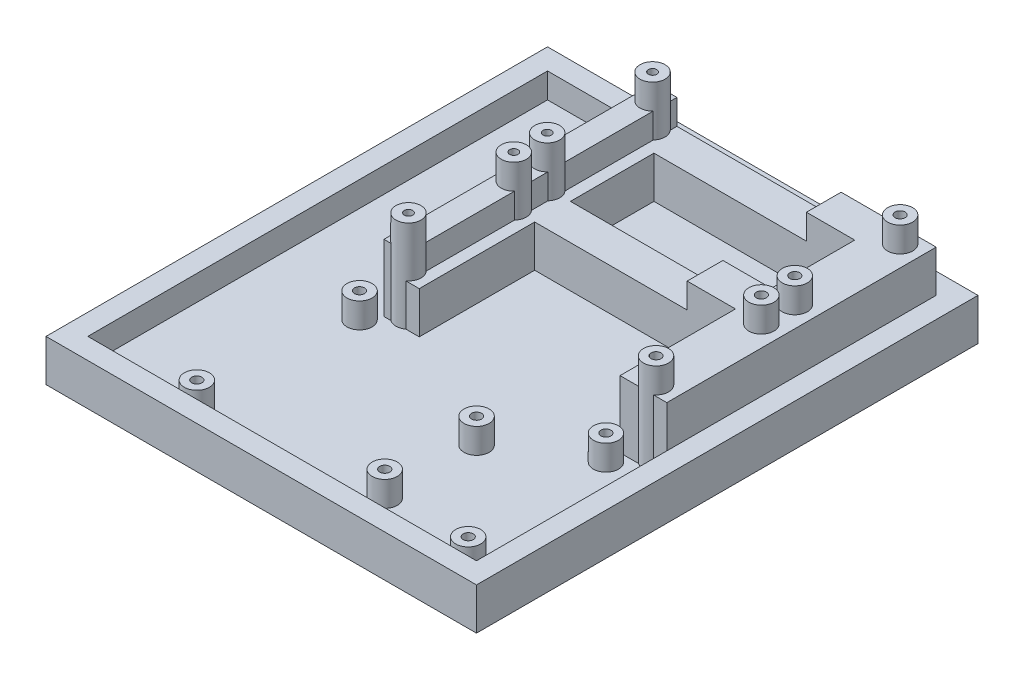
from build123d import *

# Parameters (mm, degrees)
SKETCH1_W            = 152.4
SKETCH1_H            = 152.4
BOSS_EXTRUDE1_DEPTH  = 5.08
SKETCH6_R            = 3.81
BOSS_EXTRUDE3_DEPTH  = 7.62
SKETCH7_W            = 152.4
SKETCH7_H            = 152.4
SKETCH7_W_2          = 139.7
SKETCH7_H_2          = 139.7
BOSS_EXTRUDE4_DEPTH  = 7.62
SKETCH9_R            = 3.81
BOSS_EXTRUDE6_DEPTH  = 27.94
SKETCH11_W           = 85.963722039
SKETCH11_H           = 81.851496928
BOSS_EXTRUDE9_DEPTH  = 20.32
SKETCH12_W           = 61.01453669
SKETCH12_H           = 25.385301209
SKETCH12_H_2         = 35.074856928
CUT_EXTRUDE1_DEPTH   = 20.32
SKETCH14_W           = 46.335678953
SKETCH14_H           = 46.77664
CUT_EXTRUDE2_DEPTH   = 7.62
SKETCH15_R           = 1.524
CUT_EXTRUDE3_DEPTH   = 3.81
SKETCH16_R           = 1.524
CUT_EXTRUDE4_DEPTH   = 3.81
BOSS_EXTRUDE10_START = -12.7
SKETCH18_W           = 165.1
SKETCH18_H           = 165.1
SKETCH18_W_2         = 152.4
SKETCH18_H_2         = 152.4
BOSS_EXTRUDE10_DEPTH = 12.7
SKETCH22_W           = 195.571726543
SKETCH22_H           = 199.98311887
SKETCH22_W_2         = 152.4
SKETCH22_H_2         = 152.4
CUT_EXTRUDE5_DEPTH   = 13.7
SKETCH24_W           = 21.59
SKETCH24_H           = 152.4
CUT_EXTRUDE6_DEPTH   = 13.7
SKETCH25_W           = 6.35
SKETCH25_H           = 139.7
BOSS_EXTRUDE11_DEPTH = 7.62
SKETCH26_W           = 3.556
SKETCH26_H           = 81.851496928
CUT_EXTRUDE7_DEPTH   = 7.62
BOSS_EXTRUDE12_START = -15.24
SKETCH28_R           = 3.81
SKETCH28_R_2         = 1.27
BOSS_EXTRUDE12_DEPTH = 15.24
CUT_EXTRUDE8_DEPTH   = 15.24


with BuildPart() as part:
    # Sketch1 → Boss-Extrude1 (new body)
    with BuildSketch(Plane(origin=(0, 0, 0), x_dir=(1, 0, 0), z_dir=(0, 1, 0))):
        Rectangle(SKETCH1_W, SKETCH1_H)
    extrude(amount=BOSS_EXTRUDE1_DEPTH)

    # Sketch6 → Boss-Extrude3 (add)
    with BuildSketch(Plane(origin=(0, 5.08, 0), x_dir=(1, 0, 0), z_dir=(0, 1, 0))):
        with Locations((62.26048, -64.77)):
            Circle(SKETCH6_R)
        with Locations((-20.21078, -64.77)):
            Circle(SKETCH6_R)
        with Locations((31.81096, -59.69)):
            Circle(SKETCH6_R)
        with Locations((31.81096, -31.78048)):
            Circle(SKETCH6_R)
        with Locations((55.90032, -16.55064)):
            Circle(SKETCH6_R)
        with Locations((-18.97888, -16.55064)):
            Circle(SKETCH6_R)
    extrude(amount=BOSS_EXTRUDE3_DEPTH)

    # Sketch7 → Boss-Extrude4 (add)
    with BuildSketch(Plane(origin=(0, 5.08, 0), x_dir=(1, 0, 0), z_dir=(0, 1, 0))):
        Rectangle(SKETCH7_W, SKETCH7_H)
        Rectangle(SKETCH7_W_2, SKETCH7_H_2, mode=Mode.SUBTRACT)
    extrude(amount=BOSS_EXTRUDE4_DEPTH)

    # Sketch9 → Boss-Extrude6 (add)
    with BuildSketch(Plane(origin=(0, 5.08, 0), x_dir=(1, 0, 0), z_dir=(0, 1, 0))):
        with Locations((63.5, -8.93064)):
            Circle(SKETCH9_R)
        with Locations((-11.7348, -8.93064)):
            Circle(SKETCH9_R)
        with Locations((63.5, 23.07336)):
            Circle(SKETCH9_R)
        with Locations((-11.7348, 23.07336)):
            Circle(SKETCH9_R)
        with Locations((-11.7348, 33.23336)):
            Circle(SKETCH9_R)
        with Locations((63.5, 33.23336)):
            Circle(SKETCH9_R)
        with Locations((63.5, 65.23736)):
            Circle(SKETCH9_R)
        with Locations((-11.7348, 65.23736)):
            Circle(SKETCH9_R)
    extrude(amount=BOSS_EXTRUDE6_DEPTH)

    # Sketch11 → Boss-Extrude9 (add)
    with BuildSketch(Plane(origin=(0, 5.08, 0), x_dir=(1, 0, 0), z_dir=(0, 1, 0))):
        with Locations((26.868138981, 28.924251536)):
            Rectangle(SKETCH11_W, SKETCH11_H)
    extrude(amount=BOSS_EXTRUDE9_DEPTH)

    # Sketch12 → Cut-Extrude1 (cut)
    with BuildSketch(Plane(origin=(0, 25.4, 0), x_dir=(1, 0, 0), z_dir=(0, 1, 0))):
        with Locations((25.122468345, 46.622124643)):
            Rectangle(SKETCH12_W, SKETCH12_H)
        with Locations((25.122468345, 5.535931536)):
            Rectangle(SKETCH12_W, SKETCH12_H_2)
    extrude(amount=-CUT_EXTRUDE1_DEPTH, mode=Mode.SUBTRACT)

    # Sketch14 → Cut-Extrude2 (cut)
    with BuildSketch(Plane(origin=(0, 25.4, 0), x_dir=(1, 0, 0), z_dir=(0, 1, 0))):
        with Locations((17.783039477, 46.46168)):
            Rectangle(SKETCH14_W, SKETCH14_H)
    extrude(amount=-CUT_EXTRUDE2_DEPTH, mode=Mode.SUBTRACT)

    # Sketch15 → Cut-Extrude3 (cut)
    with BuildSketch(Plane(origin=(0, 12.7, 0), x_dir=(1, 0, 0), z_dir=(0, 1, 0))):
        with Locations((-18.97888, -16.55064)):
            Circle(SKETCH15_R)
        with Locations((31.81096, -31.78048)):
            Circle(SKETCH15_R)
        with Locations((55.90032, -16.55064)):
            Circle(SKETCH15_R)
        with Locations((62.26048, -64.77)):
            Circle(SKETCH15_R)
        with Locations((31.81096, -59.69)):
            Circle(SKETCH15_R)
        with Locations((-20.21078, -64.77)):
            Circle(SKETCH15_R)
    extrude(amount=-CUT_EXTRUDE3_DEPTH, mode=Mode.SUBTRACT)

    # Sketch16 → Cut-Extrude4 (cut)
    with BuildSketch(Plane(origin=(0, 33.02, 0), x_dir=(1, 0, 0), z_dir=(0, 1, 0))):
        with Locations((63.5, 65.23736)):
            Circle(SKETCH16_R)
        with Locations((63.5, 33.23336)):
            Circle(SKETCH16_R)
        with Locations((63.5, 23.07336)):
            Circle(SKETCH16_R)
        with Locations((63.5, -8.93064)):
            Circle(SKETCH16_R)
        with Locations((-11.7348, -8.93064)):
            Circle(SKETCH16_R)
        with Locations((-11.7348, 23.07336)):
            Circle(SKETCH16_R)
        with Locations((-11.7348, 33.23336)):
            Circle(SKETCH16_R)
        with Locations((-11.7348, 65.23736)):
            Circle(SKETCH16_R)
    extrude(amount=-CUT_EXTRUDE4_DEPTH, mode=Mode.SUBTRACT)

    # Sketch18 → Boss-Extrude10 (add)
    with BuildSketch(Plane.XZ.offset(BOSS_EXTRUDE10_START)):
        Rectangle(SKETCH18_W, SKETCH18_H)
        Rectangle(SKETCH18_W_2, SKETCH18_H_2, mode=Mode.SUBTRACT)
    extrude(amount=BOSS_EXTRUDE10_DEPTH)

    # Sketch22 → Cut-Extrude5 (cut, through all)
    with BuildSketch(Plane(origin=(0, 12.7, 0), x_dir=(1, 0, 0), z_dir=(0, 1, 0))):
        with Locations((-3.578752524, -2.666785406)):
            Rectangle(SKETCH22_W, SKETCH22_H)
        Rectangle(SKETCH22_W_2, SKETCH22_H_2, mode=Mode.SUBTRACT)
    extrude(amount=-CUT_EXTRUDE5_DEPTH, mode=Mode.SUBTRACT)

    # Sketch24 → Cut-Extrude6 (cut, through all)
    with BuildSketch(Plane(origin=(0, 12.7, 0), x_dir=(1, 0, 0), z_dir=(0, 1, 0))):
        with Locations((-65.405, 0)):
            Rectangle(SKETCH24_W, SKETCH24_H)
    extrude(amount=-CUT_EXTRUDE6_DEPTH, mode=Mode.SUBTRACT)

    # Sketch25 → Boss-Extrude11 (add)
    with BuildSketch(Plane(origin=(0, 5.08, 0), x_dir=(1, 0, 0), z_dir=(0, 1, 0))):
        with Locations((-51.435, 0)):
            Rectangle(SKETCH25_W, SKETCH25_H)
    extrude(amount=BOSS_EXTRUDE11_DEPTH)

    # Sketch26 → Cut-Extrude7 (cut)
    with BuildSketch(Plane(origin=(0, 25.4, 0), x_dir=(1, 0, 0), z_dir=(0, 1, 0))):
        with Locations((-7.1628, 28.924251536)):
            Rectangle(SKETCH26_W, SKETCH26_H)
    extrude(amount=-CUT_EXTRUDE7_DEPTH, mode=Mode.SUBTRACT)

    # Sketch28 → Boss-Extrude12 (add)
    with BuildSketch(Plane(origin=(0, 33.02, 0), x_dir=(1, 0, 0), z_dir=(0, 1, 0)).offset(BOSS_EXTRUDE12_START)):
        with Locations((-11.7348, 65.23736)):
            Circle(SKETCH28_R)
        with Locations((-11.7348, 65.23736)):
            Circle(SKETCH28_R_2, mode=Mode.SUBTRACT)
        with Locations((-11.7348, 33.23336)):
            Circle(SKETCH28_R)
        with Locations((-11.7348, 33.23336)):
            Circle(SKETCH28_R_2, mode=Mode.SUBTRACT)
        with Locations((-11.7348, 23.07336)):
            Circle(SKETCH28_R)
        with Locations((-11.7348, 23.07336)):
            Circle(SKETCH28_R_2, mode=Mode.SUBTRACT)
        with Locations((-11.7348, -8.93064)):
            Circle(SKETCH28_R)
        with Locations((-11.7348, -8.93064)):
            Circle(SKETCH28_R_2, mode=Mode.SUBTRACT)
    extrude(amount=BOSS_EXTRUDE12_DEPTH)

    # Sketch29 → Cut-Extrude8 (cut)
    with BuildSketch(Plane(origin=(0, 33.02, 0), x_dir=(1, 0, 0), z_dir=(0, 1, 0))):
        with BuildLine():
            Line((-8.9408, -12.001496928), (-8.9408, -11.520941913))
            ThreePointArc((-8.9408, -11.520941913), (-9.198790453, -11.774010461), (-9.479597631, -12.001496928))
            Line((-9.479597631, -12.001496928), (-8.9408, -12.001496928))
        make_face()
    extrude(amount=-CUT_EXTRUDE8_DEPTH, mode=Mode.SUBTRACT)


solid = part.part
